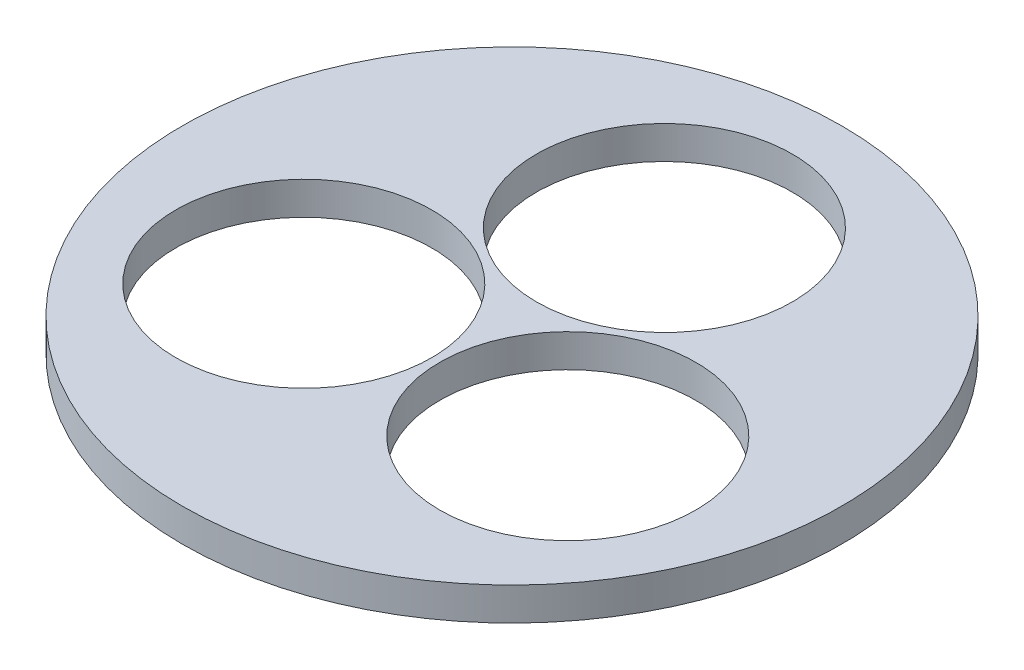
from build123d import *

# Parameters (mm, degrees)
SKETCH1_R           = 101.6
BOSS_EXTRUDE1_DEPTH = 10.16
SKETCH2_R           = 39.4716
CUT_EXTRUDE1_DEPTH  = 11.16


with BuildPart() as part:
    # Sketch1 → Boss-Extrude1 (new body)
    with BuildSketch(Plane(origin=(0, 0, 0), x_dir=(1, 0, 0), z_dir=(0, 1, 0))):
        Circle(SKETCH1_R)
    extrude(amount=BOSS_EXTRUDE1_DEPTH)

    # Sketch2 → Cut-Extrude1 (cut, through all)
    with BuildSketch(Plane(origin=(0, 10.16, 0), x_dir=(1, 0, 0), z_dir=(0, 1, 0))):
        with Locations((0, 46.99)):
            Circle(SKETCH2_R)
        with Locations((40.694533724, -23.495)):
            Circle(SKETCH2_R)
        with Locations((-40.694533724, -23.495)):
            Circle(SKETCH2_R)
    extrude(amount=-CUT_EXTRUDE1_DEPTH, mode=Mode.SUBTRACT)


solid = part.part
